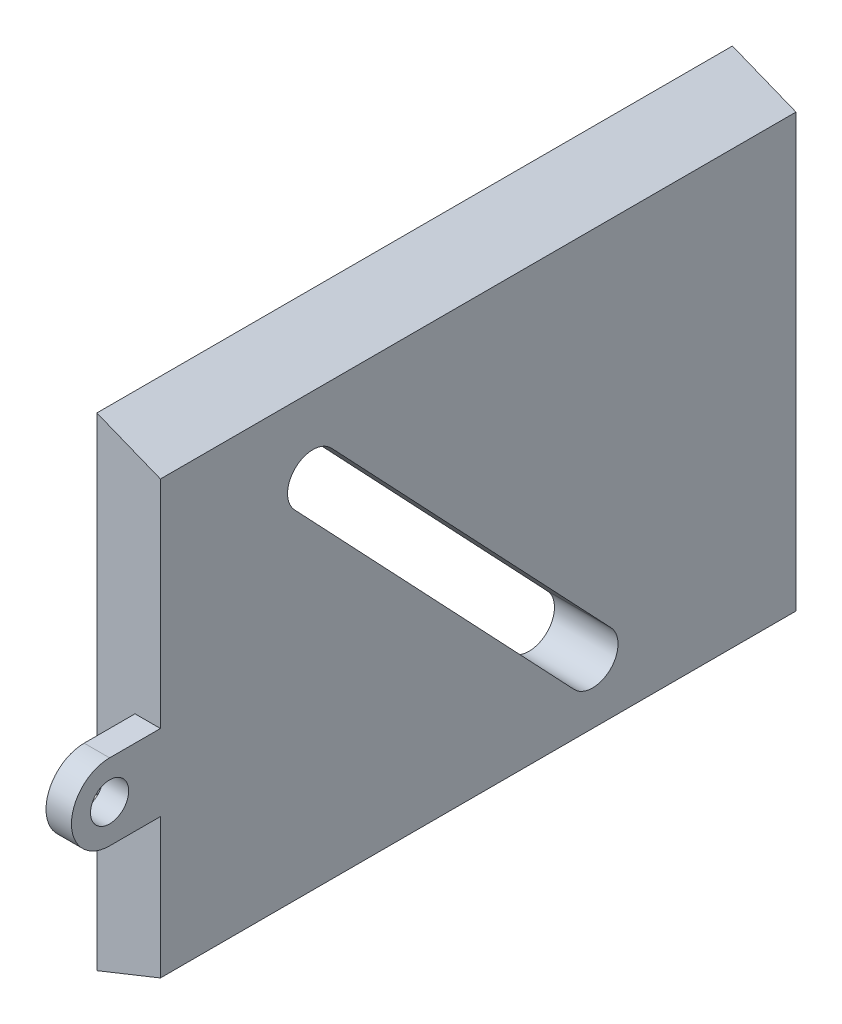
from build123d import *

# Parameters (mm, degrees)
BOSS_EXTRUDE1_DEPTH = 50
SKETCH2_R           = 1.5
BOSS_EXTRUDE2_DEPTH = 2
CUT_EXTRUDE1_DEPTH  = 6


with BuildPart() as part:
    # Sketch1 → Boss-Extrude1 (new body)
    with BuildSketch(Plane.XY):
        Polygon((5, 36), (0, 38), (0, 0), (5, 2), align=None)
    extrude(amount=BOSS_EXTRUDE1_DEPTH)

    # Sketch2 → Boss-Extrude2 (add)
    with BuildSketch(Plane(origin=(5, 0, 0), x_dir=(0, 0, -1), z_dir=(1, 0, 0))):
        with BuildLine():
            Line((-50, 13), (-54, 13))
            ThreePointArc((-54, 13), (-57, 16), (-54, 19))
            Line((-54, 19), (-50, 19))
            ThreePointArc((-50, 19), (-47, 16), (-50, 13))
        make_face()
        with Locations((-54, 16)):
            Circle(SKETCH2_R, mode=Mode.SUBTRACT)
    extrude(amount=-BOSS_EXTRUDE2_DEPTH)

    # Sketch3 → Cut-Extrude1 (cut, through all)
    with BuildSketch(Plane(origin=(5, 0, 0), x_dir=(0, 0, -1), z_dir=(1, 0, 0))):
        with BuildLine():
            Line((-36.547631245, 31.375), (-14.547631245, 8.137099923))
            ThreePointArc((-14.547631245, 8.137099923), (-14.625, 5.309731168), (-17.452368755, 5.387099923))
            Line((-17.452368755, 5.387099923), (-39.452368755, 28.625))
            ThreePointArc((-39.452368755, 28.625), (-39.375, 31.452368755), (-36.547631245, 31.375))
        make_face()
    extrude(amount=-CUT_EXTRUDE1_DEPTH, mode=Mode.SUBTRACT)


solid = part.part
